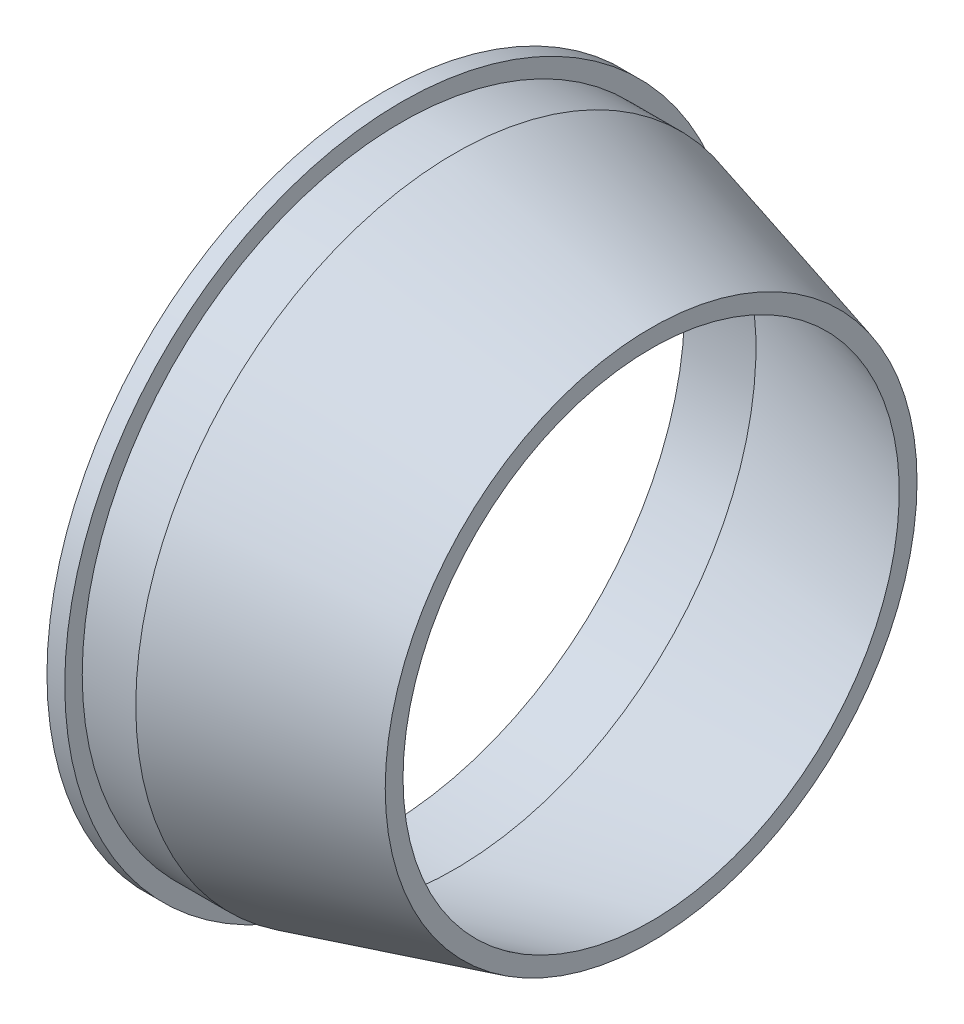
from build123d import *

# Parameters (mm, degrees)
SKETCH3_R          = 1
CUT_EXTRUDE1_DEPTH = 10


with BuildPart() as part:
    # Sketch2 → Revolve1 (revolve)
    with BuildSketch(Plane.XY):
        Polygon((0, 45), (0, 50.271149675), (2.66, 50.271149675), (2.66, 47.66), (10.66, 47.66), (40, 39.731024452), (40, 37.071024452), (10.66, 45), align=None)
    revolve(axis=Axis((0, 0, 0), (1, 0, 0)))

    # Sketch3 → Cut-Extrude1 (cut)
    with BuildSketch(Plane.ZY):
        with Locations((0, -46.5)):
            Circle(SKETCH3_R)
        with Locations((-46.5, 0)):
            Circle(SKETCH3_R)
        with Locations((0, 46.5)):
            Circle(SKETCH3_R)
        with Locations((46.5, 0)):
            Circle(SKETCH3_R)
    extrude(amount=-CUT_EXTRUDE1_DEPTH, mode=Mode.SUBTRACT)


solid = part.part
